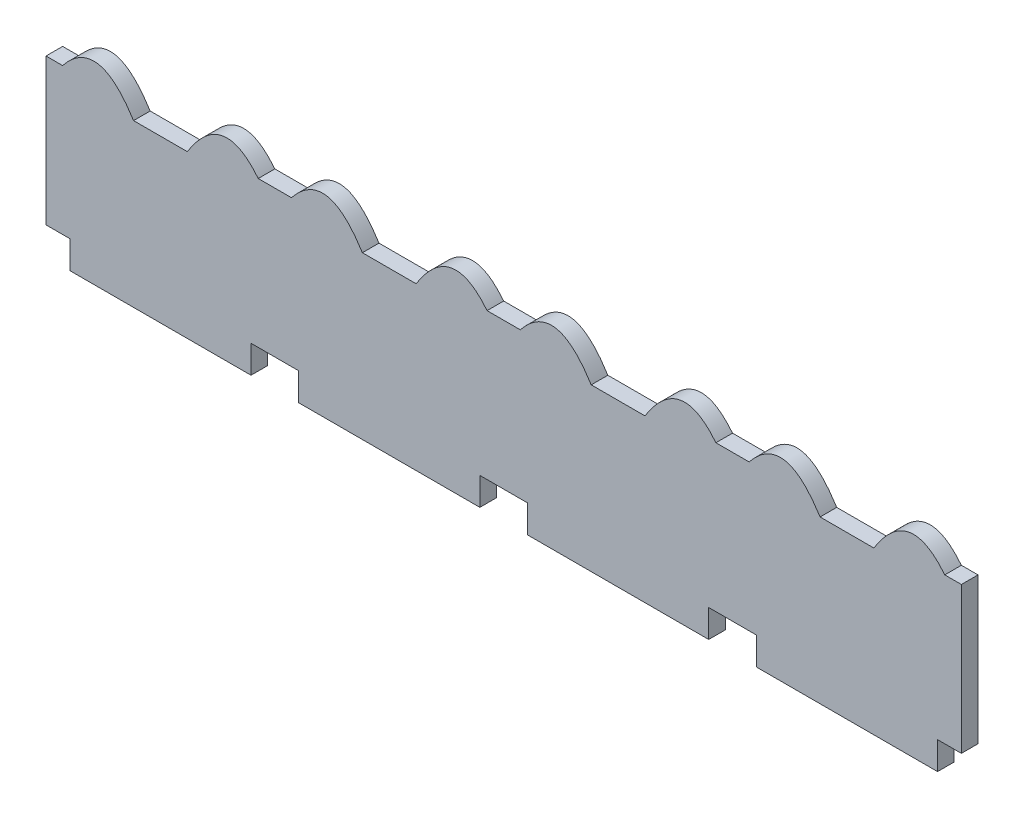
from build123d import *

# Parameters (mm, degrees)
EXTRUDE1_DEPTH = 1.5


with BuildPart() as part:
    # Sketch1 → Extrude1 (new body)
    with BuildSketch(Plane.XY):
        with BuildLine():
            Line((70.775, 15.7), (72.275, 15.7))
            Line((72.275, 15.7), (72.275, 2.5))
            Line((72.275, 2.5), (70.125, 2.5))
            Line((70.125, 2.5), (70.125, 0))
            Line((70.125, 0), (53.775, 0))
            Line((53.775, 0), (53.775, 2.5))
            Line((53.775, 2.5), (51.625, 2.5))
            Line((51.625, 2.5), (49.475, 2.5))
            Line((49.475, 2.5), (49.475, 0))
            Line((49.475, 0), (33.125, 0))
            Line((33.125, 0), (33.125, 2.5))
            Line((33.125, 2.5), (30.975, 2.5))
            Line((30.975, 2.5), (28.825, 2.5))
            Line((28.825, 2.5), (28.825, 0))
            Line((28.825, 0), (12.475, 0))
            Line((12.475, 0), (12.475, 2.5))
            Line((12.475, 2.5), (10.325, 2.5))
            Line((10.325, 2.5), (8.175, 2.5))
            Line((8.175, 2.5), (8.175, 0))
            Line((8.175, 0), (-8.175, 0))
            Line((-8.175, 0), (-8.175, 2.5))
            Line((-8.175, 2.5), (-10.325, 2.5))
            Line((-10.325, 2.5), (-10.325, 15.7))
            Line((-10.325, 15.7), (-8.825000006, 15.7))
            add(Edge.make_bspline(
                [(-8.825000006, 15.7), (-5.625000003, 19.70356859), (-2.425, 14.6)],
                knots=[0, 0, 0, 1, 1, 1], degree=2))
            Line((-2.425, 14.6), (2.425000009, 14.6))
            add(Edge.make_bspline(
                [(2.425000009, 14.6), (5.625000004, 19.703568583), (8.825, 15.7)],
                knots=[0, 0, 0, 1, 1, 1], degree=2))
            Line((8.825, 15.7), (10.325, 15.7))
            Line((10.325, 15.7), (11.824999994, 15.7))
            add(Edge.make_bspline(
                [(11.824999994, 15.7), (15.024999997, 19.70356859), (18.225, 14.6)],
                knots=[0, 0, 0, 1, 1, 1], degree=2))
            Line((18.225, 14.6), (23.075000009, 14.6))
            add(Edge.make_bspline(
                [(23.075000009, 14.6), (26.275000004, 19.703568583), (29.475, 15.7)],
                knots=[0, 0, 0, 1, 1, 1], degree=2))
            Line((29.475, 15.7), (30.975, 15.7))
            Line((30.975, 15.7), (32.474999994, 15.7))
            add(Edge.make_bspline(
                [(32.474999994, 15.7), (35.674999997, 19.70356859), (38.875, 14.6)],
                knots=[0, 0, 0, 1, 1, 1], degree=2))
            Line((38.875, 14.6), (43.725000009, 14.6))
            add(Edge.make_bspline(
                [(43.725000009, 14.6), (46.925000004, 19.703568583), (50.125, 15.7)],
                knots=[0, 0, 0, 1, 1, 1], degree=2))
            Line((50.125, 15.7), (51.625, 15.7))
            Line((51.625, 15.7), (53.124999994, 15.7))
            add(Edge.make_bspline(
                [(53.124999994, 15.7), (56.324999997, 19.70356859), (59.525, 14.6)],
                knots=[0, 0, 0, 1, 1, 1], degree=2))
            Line((59.525, 14.6), (64.375000009, 14.6))
            add(Edge.make_bspline(
                [(64.375000009, 14.6), (67.575000004, 19.703568583), (70.775, 15.7)],
                knots=[0, 0, 0, 1, 1, 1], degree=2))
        make_face()
    extrude(amount=EXTRUDE1_DEPTH)


solid = part.part
